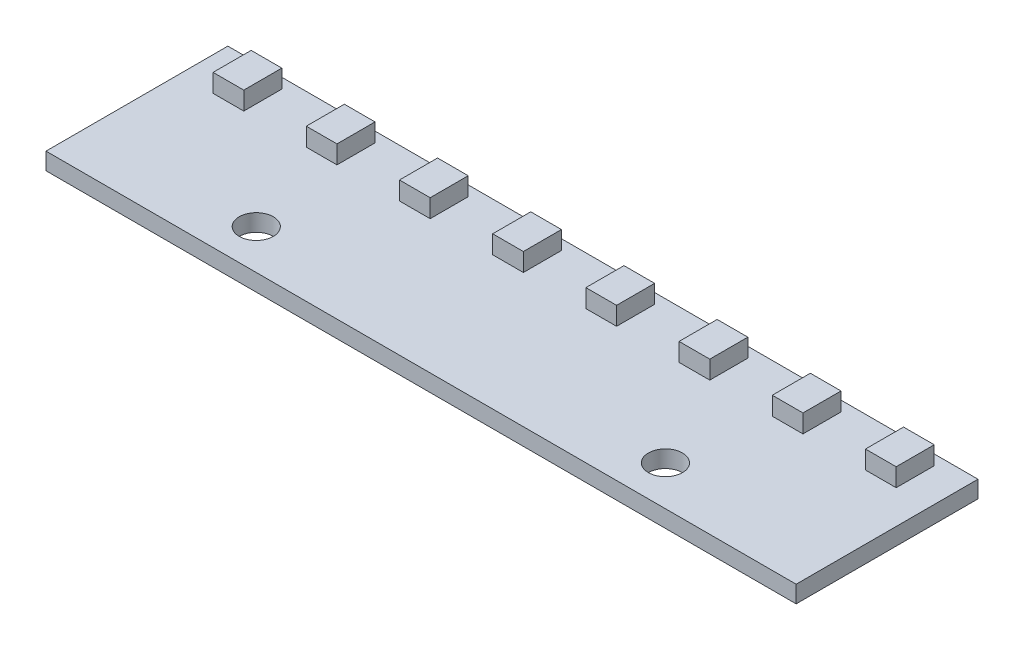
from build123d import *

# Parameters (mm, degrees)
SKETCH1_W           = 66
SKETCH1_H           = 16
SKETCH1_R           = 1.5
BOSS_EXTRUDE1_DEPTH = 1.5
SKETCH4_W           = 2.7
SKETCH4_H           = 3.35
BOSS_EXTRUDE4_DEPTH = 1.6


with BuildPart() as part:
    # Sketch1 → Boss-Extrude1 (new body)
    with BuildSketch(Plane(origin=(0, 0, 0), x_dir=(1, 0, 0), z_dir=(0, 1, 0))):
        Rectangle(SKETCH1_W, SKETCH1_H)
        with Locations((-18, -4.5)):
            Circle(SKETCH1_R, mode=Mode.SUBTRACT)
        with Locations((18, -4.5)):
            Circle(SKETCH1_R, mode=Mode.SUBTRACT)
    extrude(amount=-BOSS_EXTRUDE1_DEPTH)

    # Sketch4 → Boss-Extrude4 (add)
    with BuildSketch(Plane(origin=(0, 0, 0), x_dir=(1, 0, 0), z_dir=(0, 1, 0))):
        with Locations((-4.1, 5.425)):
            Rectangle(SKETCH4_W, SKETCH4_H)
        with Locations((4.1, 5.425)):
            Rectangle(SKETCH4_W, SKETCH4_H)
        with Locations((12.3, 5.425)):
            Rectangle(SKETCH4_W, SKETCH4_H)
        with Locations((20.5, 5.425)):
            Rectangle(SKETCH4_W, SKETCH4_H)
        with Locations((28.7, 5.425)):
            Rectangle(SKETCH4_W, SKETCH4_H)
        with Locations((-12.3, 5.425)):
            Rectangle(SKETCH4_W, SKETCH4_H)
        with Locations((-28.7, 5.425)):
            Rectangle(SKETCH4_W, SKETCH4_H)
        with Locations((-20.5, 5.425)):
            Rectangle(SKETCH4_W, SKETCH4_H)
    extrude(amount=BOSS_EXTRUDE4_DEPTH)


solid = part.part
